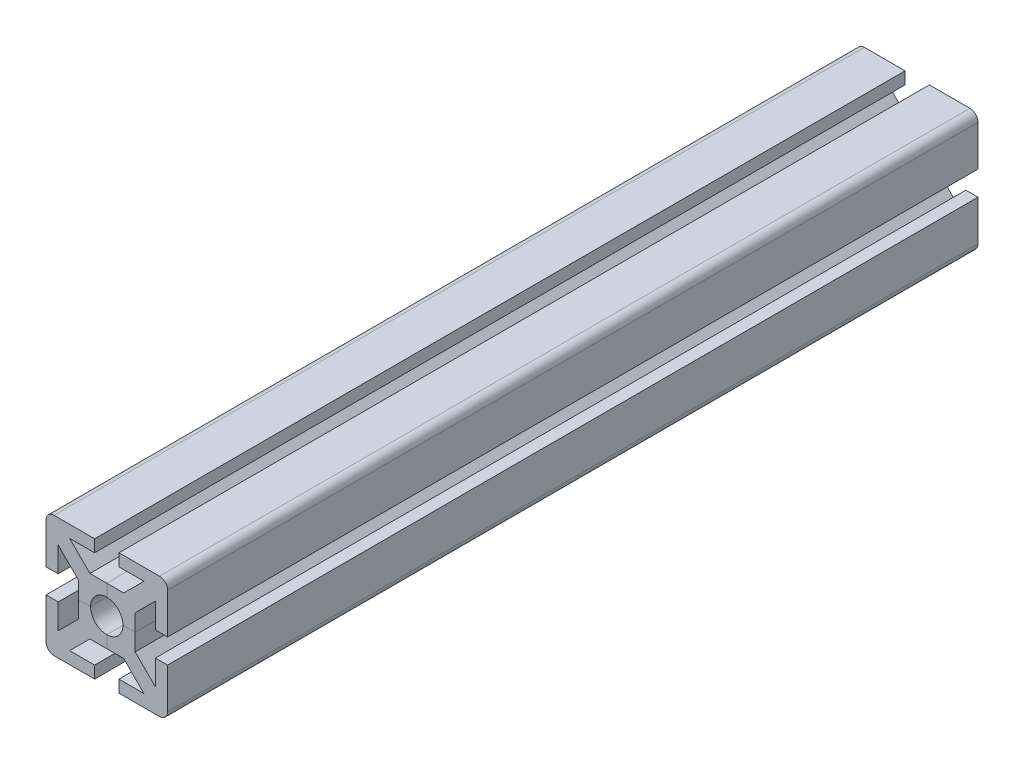
from build123d import *

# Parameters (mm, degrees)
SALIENTE_EXTRUIR1_DEPTH = 100
REDONDEO1_R             = 2
MATRIZC4_COUNT          = 4


with BuildPart() as part:
    # Croquis1 → Saliente-Extruir1 (new body, symmetric)
    with BuildSketch(Plane.XY):
        with BuildLine():
            Line((0, 4), (0, 7))
            Line((0, 7), (4.171572875, 7))
            Line((4.171572875, 7), (9.171572875, 12))
            Line((9.171572875, 12), (3, 12))
            Line((3, 12), (3, 15))
            Line((3, 15), (15, 15))
            Line((15, 15), (2.828427125, 2.828427125))
            ThreePointArc((2.828427125, 2.828427125), (1.530733729, 3.69551813), (0, 4))
        make_face()
    saliente_extruir1 = extrude(amount=SALIENTE_EXTRUIR1_DEPTH, both=True)

    # Simetría1: Saliente-Extruir1 across plane
    add(saliente_extruir1.mirror(Plane(origin=(2.828427125, 2.828427125, 100), x_dir=(0, 0, 1), z_dir=(-0.707106781, 0.707106781, 0))))

    # Redondeo1
    redondeo1_edges = [part.edges().sort_by_distance(p)[0] for p in [
        (15, 15, 0),
    ]]
    fillet(redondeo1_edges, radius=REDONDEO1_R)


with BuildPart() as matrizc4_1:
    # MatrizC4: pattern copy
    add(part.part.rotate(Axis((0, 0, 0), (0, 0, 1)), 1 * 360 / MATRIZC4_COUNT))


with BuildPart() as matrizc4_2:
    # MatrizC4: pattern copy
    add(part.part.rotate(Axis((0, 0, 0), (0, 0, 1)), 2 * 360 / MATRIZC4_COUNT))


with BuildPart() as matrizc4_3:
    # MatrizC4: pattern copy
    add(part.part.rotate(Axis((0, 0, 0), (0, 0, 1)), 3 * 360 / MATRIZC4_COUNT))


solid = Compound([part.part, matrizc4_1.part, matrizc4_2.part, matrizc4_3.part])
